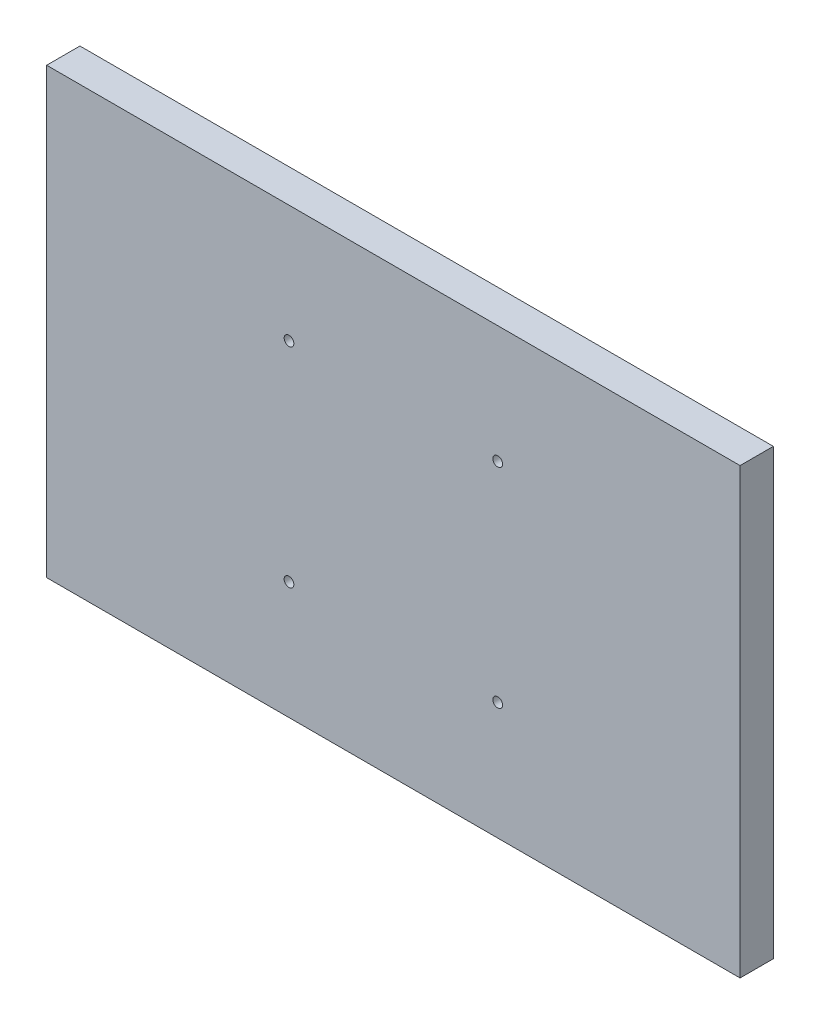
from build123d import *

# Parameters (mm, degrees)
SKETCH_1_W      = 250
SKETCH_1_H      = 160
SKETCH_1_R      = 1.75
EXTRUDE_1_DEPTH = 12


with BuildPart() as part:
    # 草图1 → 凸台-拉伸1 (new body)
    with BuildSketch(Plane.XY):
        Rectangle(SKETCH_1_W, SKETCH_1_H)
        with Locations((37.625, 37.625)):
            Circle(SKETCH_1_R, mode=Mode.SUBTRACT)
        with Locations((37.625, -37.625)):
            Circle(SKETCH_1_R, mode=Mode.SUBTRACT)
        with Locations((-37.625, -37.625)):
            Circle(SKETCH_1_R, mode=Mode.SUBTRACT)
        with Locations((-37.625, 37.625)):
            Circle(SKETCH_1_R, mode=Mode.SUBTRACT)
    extrude(amount=EXTRUDE_1_DEPTH)


solid = part.part
